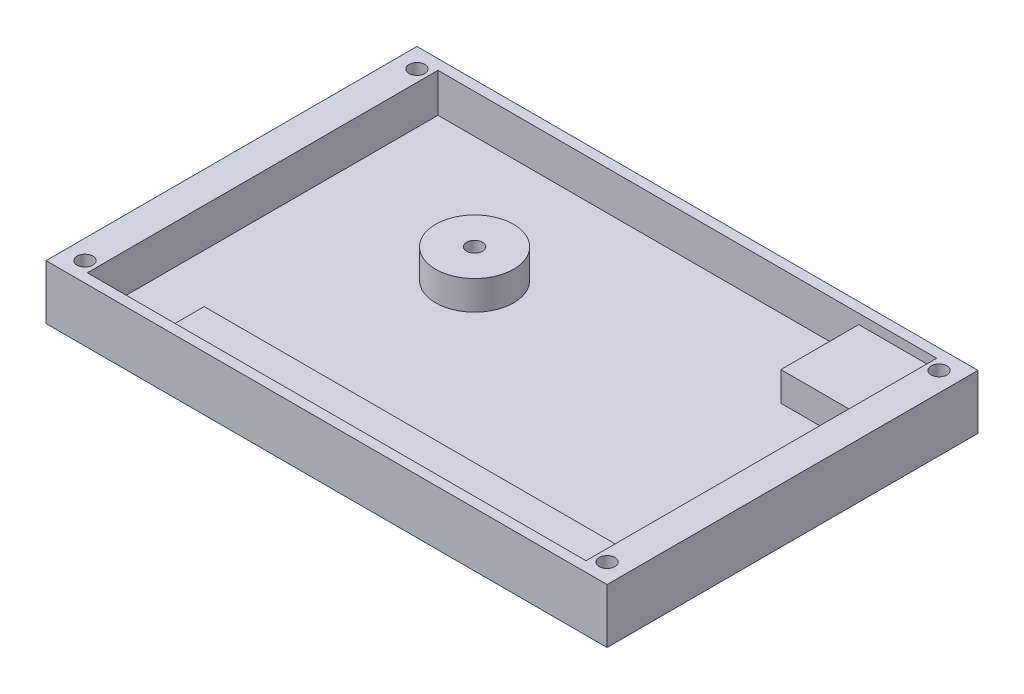
from build123d import *

# Parameters (mm, degrees)
SKETCH1_W           = 91.44
SKETCH1_H           = 60.452
BOSS_EXTRUDE1_DEPTH = 8.89
SKETCH2_W           = 81.28
SKETCH2_H           = 57.15
CUT_EXTRUDE1_DEPTH  = 1.6002
SKETCH3_R           = 6.35
SKETCH3_R_2         = 1.28905
CUT_EXTRUDE2_DEPTH  = 4.7498
SKETCH4_R           = 1.28905
CUT_EXTRUDE3_DEPTH  = 56.524423239


with BuildPart() as part:
    # Sketch1 → Boss-Extrude1 (new body)
    with BuildSketch(Plane(origin=(0, 0, 0), x_dir=(1, 0, 0), z_dir=(0, 1, 0))):
        Rectangle(SKETCH1_W, SKETCH1_H)
    extrude(amount=BOSS_EXTRUDE1_DEPTH)

    # Sketch2 → Cut-Extrude1 (cut)
    with BuildSketch(Plane(origin=(0, 8.89, 0), x_dir=(1, 0, 0), z_dir=(0, 1, 0))):
        Rectangle(SKETCH2_W, SKETCH2_H)
    extrude(amount=-CUT_EXTRUDE1_DEPTH, mode=Mode.SUBTRACT)

    # Sketch3 → Cut-Extrude2 (cut)
    with BuildSketch(Plane(origin=(0, 7.2898, 0), x_dir=(1, 0, 0), z_dir=(0, 1, 0))):
        Polygon((-40.64, 28.575), (27.94, 28.575), (27.94, 15.875), (40.64, 15.875), (40.64, -22.225), (-27.94, -22.225), (-27.94, -28.575), (-40.64, -28.575), (-40.64, -22.225), align=None)
        with Locations(Location((-14.351, 8.255, 0), (0, 0, 270))):
            Circle(SKETCH3_R, mode=Mode.SUBTRACT)
        with Locations(Location((-14.351, 8.255, 0), (0, 0, 270))):
            Circle(SKETCH3_R_2)
    extrude(amount=-CUT_EXTRUDE2_DEPTH, mode=Mode.SUBTRACT)

    # Sketch4 → Cut-Extrude3 (cut, through all)
    with BuildSketch(Plane(origin=(0, 8.89, 0), x_dir=(1, 0, 0), z_dir=(0, 1, 0))):
        with Locations(Location((-42.545, 27.051, 0), (0, 0, 270))):
            Circle(SKETCH4_R)
        with Locations(Location((-42.545, -27.051, 0), (0, 0, 270))):
            Circle(SKETCH4_R)
        with Locations(Location((42.545, -27.051, 0), (0, 0, 270))):
            Circle(SKETCH4_R)
        with Locations(Location((42.545, 27.051, 0), (0, 0, 270))):
            Circle(SKETCH4_R)
    extrude(amount=-CUT_EXTRUDE3_DEPTH, mode=Mode.SUBTRACT)


solid = part.part
